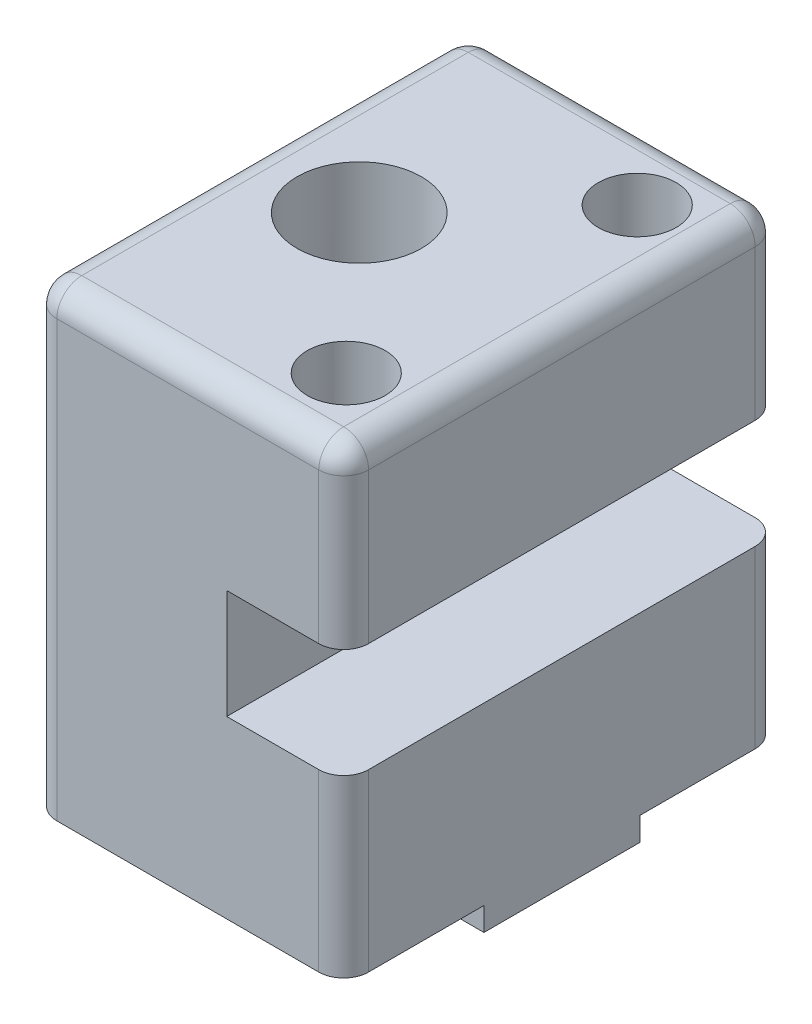
from build123d import *

# Parameters (mm, degrees)
BOSS_EXTRUDE1_DEPTH     = 22.225
SKETCH4_W               = 15.875
SKETCH4_H               = 2.38125
BOSS_EXTRUDE2_DEPTH     = 31.75
SKETCH2_R               = 6.33095
CUT_EXTRUDE1_DEPTH      = 1
CUT_EXTRUDE1_DEPTH_BACK = 50.2125
CUT_EXTRUDE2_REACH      = 51.212
SKETCH3_R               = 3.96875
FILLET1_R               = 2.54


with BuildPart() as part:
    # Sketch1 → Boss-Extrude1 (new body, symmetric)
    with BuildSketch(Plane.XY):
        Polygon((15.875, 23.415625), (-15.875, 23.415625), (-15.875, -23.415625), (15.875, -23.415625), (15.875, -5.55625), (3.96875, -5.55625), (3.96875, 5.55625), (15.875, 5.55625), align=None)
    extrude(amount=BOSS_EXTRUDE1_DEPTH, both=True)

    # Sketch4 → Boss-Extrude2 (add, through all)
    with BuildSketch(Plane(origin=(15.875, 0, 0), x_dir=(0, 0, -1), z_dir=(1, 0, 0))):
        with Locations((0, -24.60625)):
            Rectangle(SKETCH4_W, SKETCH4_H)
    extrude(amount=-BOSS_EXTRUDE2_DEPTH)

    # Sketch2 → Cut-Extrude1 (cut, two sides)
    with BuildSketch(Plane(origin=(0, 23.415625, 0), x_dir=(1, 0, 0), z_dir=(0, 1, 0))) as cut_extrude1_sk:
        with Locations((-4.7625, 0)):
            Circle(SKETCH2_R)
    extrude(amount=CUT_EXTRUDE1_DEPTH, mode=Mode.SUBTRACT)
    extrude(cut_extrude1_sk.sketch, amount=-CUT_EXTRUDE1_DEPTH_BACK, mode=Mode.SUBTRACT)

    # Sketch3 → Cut-Extrude2 (cut, up to next)
    with BuildSketch(Plane(origin=(0, 23.415625, 0), x_dir=(1, 0, 0), z_dir=(0, 1, 0)), mode=Mode.PRIVATE) as cut_extrude2_sk1:
        with Locations((8.73125, 14.816666667)):
            Circle(SKETCH3_R)
    cut_extrude2_tool1 = extrude(cut_extrude2_sk1.sketch, amount=-CUT_EXTRUDE2_REACH, mode=Mode.PRIVATE) & part.part
    add(cut_extrude2_tool1.solids().sort_by_distance((8.73125, 23.415625, -14.816667))[0], mode=Mode.SUBTRACT)
    # Sketch3 → Cut-Extrude2 (cut, up to next)
    with BuildSketch(Plane(origin=(0, 23.415625, 0), x_dir=(1, 0, 0), z_dir=(0, 1, 0)), mode=Mode.PRIVATE) as cut_extrude2_sk2:
        with Locations((8.73125, -14.816666667)):
            Circle(SKETCH3_R)
    cut_extrude2_tool2 = extrude(cut_extrude2_sk2.sketch, amount=-CUT_EXTRUDE2_REACH, mode=Mode.PRIVATE) & part.part
    add(cut_extrude2_tool2.solids().sort_by_distance((8.73125, 23.415625, 14.816667))[0], mode=Mode.SUBTRACT)

    # Fillet1
    fillet1_edges = [part.edges().sort_by_distance(p)[0] for p in [
        (15.875, -14.4859375, 22.225),
        (-15.875, 0, -22.225),
        (-15.875, 23.415625, 0),
        (15.875, 23.415625, 0),
        (15.875, 14.4859375, 22.225),
        (0, 23.415625, 22.225),
        (-15.875, 0, 22.225),
        (0, 23.415625, -22.225),
        (15.875, 14.4859375, -22.225),
        (15.875, -14.4859375, -22.225),
    ]]
    fillet(fillet1_edges, radius=FILLET1_R)


solid = part.part
